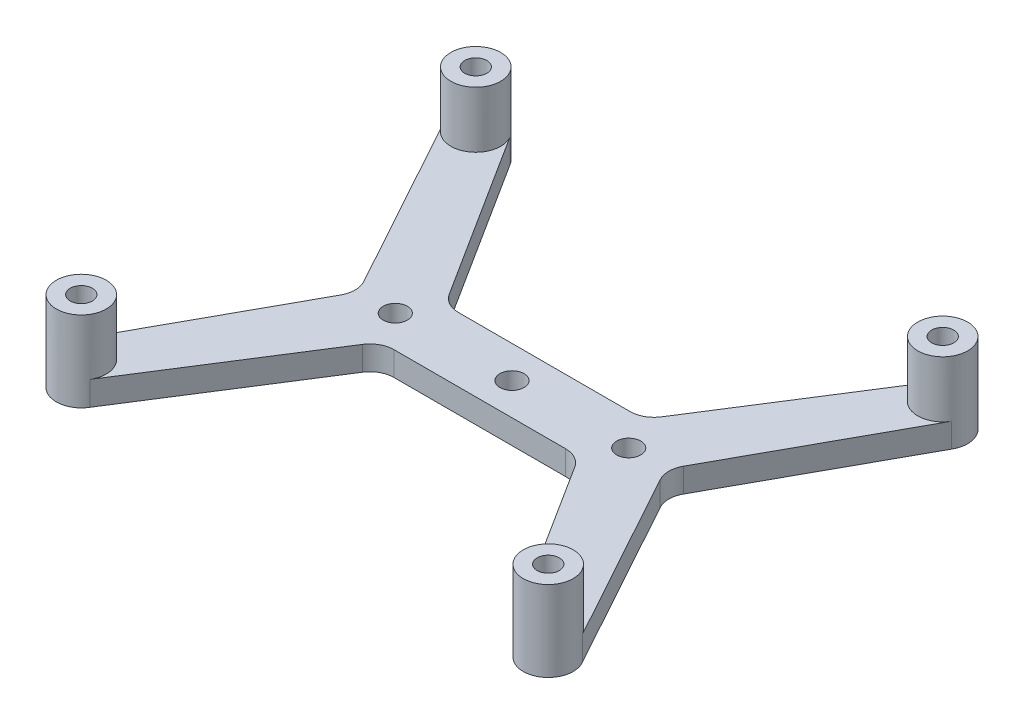
from build123d import *

# Parameters (mm, degrees)
SKETCH1_R           = 1.5
SKETCH1_R_2         = 4
SKETCH1_R_3         = 3.1
SKETCH1_R_4         = 1.375
BOSS_EXTRUDE1_DEPTH = 3
SKETCH2_R           = 3.1
SKETCH2_R_2         = 1.375
BOSS_EXTRUDE2_DEPTH = 7
FILLET4_R           = 3


with BuildPart() as part:
    # Sketch1 → Boss-Extrude1 (new body)
    with BuildSketch(Plane(origin=(0, 0, 0), x_dir=(1, 0, 0), z_dir=(0, 1, 0))):
        with BuildLine():
            ThreePointArc((10.93588599, 22.68421055), (10.5, 24.5), (10.93588599, 26.31578945))
            Line((10.93588599, 26.31578945), (9.937320588, 24.5))
            Line((9.937320588, 24.5), (10.93588599, 22.68421055))
        make_face()
        with BuildLine():
            Line((16.695320866, 28.5), (14.5, 28.5))
            ThreePointArc((14.5, 28.5), (16.370485645, 28.035715409), (17.806752459, 26.750641726))
            Line((17.806752459, 26.750641726), (16.695320866, 28.5))
        make_face()
        with BuildLine():
            Line((14.5, 20.5), (16.695320866, 20.5))
            Line((16.695320866, 20.5), (17.806752459, 22.249358274))
            ThreePointArc((17.806752459, 22.249358274), (16.370485645, 20.964284591), (14.5, 20.5))
        make_face()
        with BuildLine():
            ThreePointArc((17.806752459, 26.750641726), (16.370485645, 28.035715409), (14.5, 28.5))
            ThreePointArc((14.5, 28.5), (12.518729486, 27.974847788), (11.057693269, 26.537283576))
            Line((11.057693269, 26.537283576), (10.93588599, 26.31578945))
            ThreePointArc((10.93588599, 26.31578945), (10.5, 24.5), (10.93588599, 22.68421055))
            Line((10.93588599, 22.68421055), (11.057693269, 22.462716424))
            ThreePointArc((11.057693269, 22.462716424), (12.518729486, 21.025152212), (14.5, 20.5))
            ThreePointArc((14.5, 20.5), (16.370485645, 20.964284591), (17.806752459, 22.249358274))
            Line((17.806752459, 22.249358274), (17.942306731, 22.462716424))
            ThreePointArc((17.942306731, 22.462716424), (18.35805825, 23.443881381), (18.5, 24.5))
            ThreePointArc((18.5, 24.5), (18.35805825, 25.556118619), (17.942306731, 26.537283576))
            Line((17.942306731, 26.537283576), (17.806752459, 26.750641726))
        make_face()
        with Locations((14.5, 24.5)):
            Circle(SKETCH1_R, mode=Mode.SUBTRACT)
        with BuildLine():
            Line((29, 28.5), (16.695320866, 28.5))
            Line((16.695320866, 28.5), (17.806752459, 26.750641726))
            ThreePointArc((17.806752459, 26.750641726), (17.876215398, 26.645033703), (17.942306731, 26.537283576))
            ThreePointArc((17.942306731, 26.537283576), (18.35805825, 25.556118619), (18.5, 24.5))
            ThreePointArc((18.5, 24.5), (18.35805825, 23.443881381), (17.942306731, 22.462716424))
            ThreePointArc((17.942306731, 22.462716424), (17.876215398, 22.354966297), (17.806752459, 22.249358274))
            Line((17.806752459, 22.249358274), (16.695320866, 20.5))
            Line((16.695320866, 20.5), (29, 20.5))
            ThreePointArc((29, 20.5), (25, 24.5), (29, 28.5))
        make_face()
        with Locations((29, 24.5)):
            Circle(SKETCH1_R_2)
        with Locations((29, 24.5)):
            Circle(SKETCH1_R, mode=Mode.SUBTRACT)
        with BuildLine():
            Line((41.304679134, 28.5), (29, 28.5))
            ThreePointArc((29, 28.5), (31.828427125, 27.328427125), (33, 24.5))
            ThreePointArc((33, 24.5), (31.828427125, 21.671572875), (29, 20.5))
            Line((29, 20.5), (41.304679134, 20.5))
            Line((41.304679134, 20.5), (40.193247541, 22.249358274))
            ThreePointArc((40.193247541, 22.249358274), (40.123784602, 22.354966297), (40.057693269, 22.462716424))
            ThreePointArc((40.057693269, 22.462716424), (39.5, 24.5), (40.057693269, 26.537283576))
            ThreePointArc((40.057693269, 26.537283576), (40.123784602, 26.645033703), (40.193247541, 26.750641726))
            Line((40.193247541, 26.750641726), (41.304679134, 28.5))
        make_face()
        with BuildLine():
            Line((40.193247541, 22.249358274), (41.304679134, 20.5))
            Line((41.304679134, 20.5), (43.5, 20.5))
            ThreePointArc((43.5, 20.5), (41.629514355, 20.964284591), (40.193247541, 22.249358274))
        make_face()
        with BuildLine():
            Line((43.5, 28.5), (41.304679134, 28.5))
            Line((41.304679134, 28.5), (40.193247541, 26.750641726))
            ThreePointArc((40.193247541, 26.750641726), (41.629514355, 28.035715409), (43.5, 28.5))
        make_face()
        with BuildLine():
            Line((48.062679412, 24.5), (47.06411401, 26.31578945))
            ThreePointArc((47.06411401, 26.31578945), (47.389502284, 25.433687303), (47.5, 24.5))
            ThreePointArc((47.5, 24.5), (47.389502284, 23.566312697), (47.06411401, 22.68421055))
            Line((47.06411401, 22.68421055), (48.062679412, 24.5))
        make_face()
        with BuildLine():
            ThreePointArc((46.942306731, 26.537283576), (45.481270514, 27.974847788), (43.5, 28.5))
            ThreePointArc((43.5, 28.5), (41.629514355, 28.035715409), (40.193247541, 26.750641726))
            Line((40.193247541, 26.750641726), (40.057693269, 26.537283576))
            ThreePointArc((40.057693269, 26.537283576), (39.5, 24.5), (40.057693269, 22.462716424))
            Line((40.057693269, 22.462716424), (40.193247541, 22.249358274))
            ThreePointArc((40.193247541, 22.249358274), (41.629514355, 20.964284591), (43.5, 20.5))
            ThreePointArc((43.5, 20.5), (45.481270514, 21.025152212), (46.942306731, 22.462716424))
            Line((46.942306731, 22.462716424), (47.06411401, 22.68421055))
            ThreePointArc((47.06411401, 22.68421055), (47.389502284, 23.566312697), (47.5, 24.5))
            ThreePointArc((47.5, 24.5), (47.389502284, 25.433687303), (47.06411401, 26.31578945))
            Line((47.06411401, 26.31578945), (46.942306731, 26.537283576))
        make_face()
        with Locations((43.5, 24.5)):
            Circle(SKETCH1_R, mode=Mode.SUBTRACT)
        with BuildLine():
            Line((43.5, 20.5), (41.304679134, 20.5))
            Line((41.304679134, 20.5), (55.332212283, -1.578894771))
            ThreePointArc((55.332212283, -1.578894771), (56.421105229, 2.667787717), (60.667787717, 1.578894771))
            Line((60.667787717, 1.578894771), (48.062679412, 24.5))
            Line((48.062679412, 24.5), (47.06411401, 22.68421055))
            ThreePointArc((47.06411401, 22.68421055), (47.004960458, 22.572501054), (46.942306731, 22.462716424))
            ThreePointArc((46.942306731, 22.462716424), (45.481270514, 21.025152212), (43.5, 20.5))
        make_face()
        with BuildLine():
            Line((55.332212283, 50.578894771), (41.304679134, 28.5))
            Line((41.304679134, 28.5), (43.5, 28.5))
            ThreePointArc((43.5, 28.5), (45.481270514, 27.974847788), (46.942306731, 26.537283576))
            ThreePointArc((46.942306731, 26.537283576), (47.004960458, 26.427498946), (47.06411401, 26.31578945))
            Line((47.06411401, 26.31578945), (48.062679412, 24.5))
            Line((48.062679412, 24.5), (60.667787717, 47.421105229))
            ThreePointArc((60.667787717, 47.421105229), (56.421105229, 46.332212283), (55.332212283, 50.578894771))
        make_face()
        with BuildLine():
            Line((10.93588599, 22.68421055), (9.937320588, 24.5))
            Line((9.937320588, 24.5), (-2.667787717, 1.578894771))
            ThreePointArc((-2.667787717, 1.578894771), (0.81849193, 2.989995144), (3.1, 0))
            ThreePointArc((3.1, 0), (2.989995144, -0.81849193), (2.667787717, -1.578894771))
            Line((2.667787717, -1.578894771), (16.695320866, 20.5))
            Line((16.695320866, 20.5), (14.5, 20.5))
            ThreePointArc((14.5, 20.5), (12.518729486, 21.025152212), (11.057693269, 22.462716424))
            ThreePointArc((11.057693269, 22.462716424), (10.995039542, 22.572501054), (10.93588599, 22.68421055))
        make_face()
        Circle(SKETCH1_R_3)
        Circle(SKETCH1_R_4, mode=Mode.SUBTRACT)
        with Locations((0, 49)):
            Circle(SKETCH1_R_3)
        with Locations((0, 49)):
            Circle(SKETCH1_R_4, mode=Mode.SUBTRACT)
        with BuildLine():
            ThreePointArc((11.057693269, 26.537283576), (12.518729486, 27.974847788), (14.5, 28.5))
            Line((14.5, 28.5), (16.695320866, 28.5))
            Line((16.695320866, 28.5), (2.667787717, 50.578894771))
            ThreePointArc((2.667787717, 50.578894771), (2.989995144, 49.81849193), (3.1, 49))
            ThreePointArc((3.1, 49), (0.81849193, 46.010004856), (-2.667787717, 47.421105229))
            Line((-2.667787717, 47.421105229), (9.937320588, 24.5))
            Line((9.937320588, 24.5), (10.93588599, 26.31578945))
            ThreePointArc((10.93588599, 26.31578945), (10.995039542, 26.427498946), (11.057693269, 26.537283576))
        make_face()
        with Locations((58, 49)):
            Circle(SKETCH1_R_3)
        with Locations((58, 49)):
            Circle(SKETCH1_R_4, mode=Mode.SUBTRACT)
        with Locations((58, 0)):
            Circle(SKETCH1_R_3)
        with Locations((58, 0)):
            Circle(SKETCH1_R_4, mode=Mode.SUBTRACT)
    extrude(amount=BOSS_EXTRUDE1_DEPTH)

    # Sketch2 → Boss-Extrude2 (add)
    with BuildSketch(Plane(origin=(0, 3, 0), x_dir=(1, 0, 0), z_dir=(0, 1, 0))):
        with Locations((0, 49)):
            Circle(SKETCH2_R)
        with Locations((0, 49)):
            Circle(SKETCH2_R_2, mode=Mode.SUBTRACT)
        with Locations((58, 49)):
            Circle(SKETCH2_R)
        with Locations((58, 49)):
            Circle(SKETCH2_R_2, mode=Mode.SUBTRACT)
        with Locations((58, 0)):
            Circle(SKETCH2_R)
        with Locations((58, 0)):
            Circle(SKETCH2_R_2, mode=Mode.SUBTRACT)
        Circle(SKETCH2_R)
        Circle(SKETCH2_R_2, mode=Mode.SUBTRACT)
    extrude(amount=BOSS_EXTRUDE2_DEPTH)

    # Fillet4
    fillet4_edges = [part.edges().sort_by_distance(p)[0] for p in [
        (41.304679134, 1.5, -20.5),
        (16.695320866, 1.5, -20.5),
        (9.937320588, 1.5, -24.5),
        (16.695320866, 1.5, -28.5),
        (41.304679134, 1.5, -28.5),
        (48.062679412, 1.5, -24.5),
    ]]
    fillet(fillet4_edges, radius=FILLET4_R)


solid = part.part
